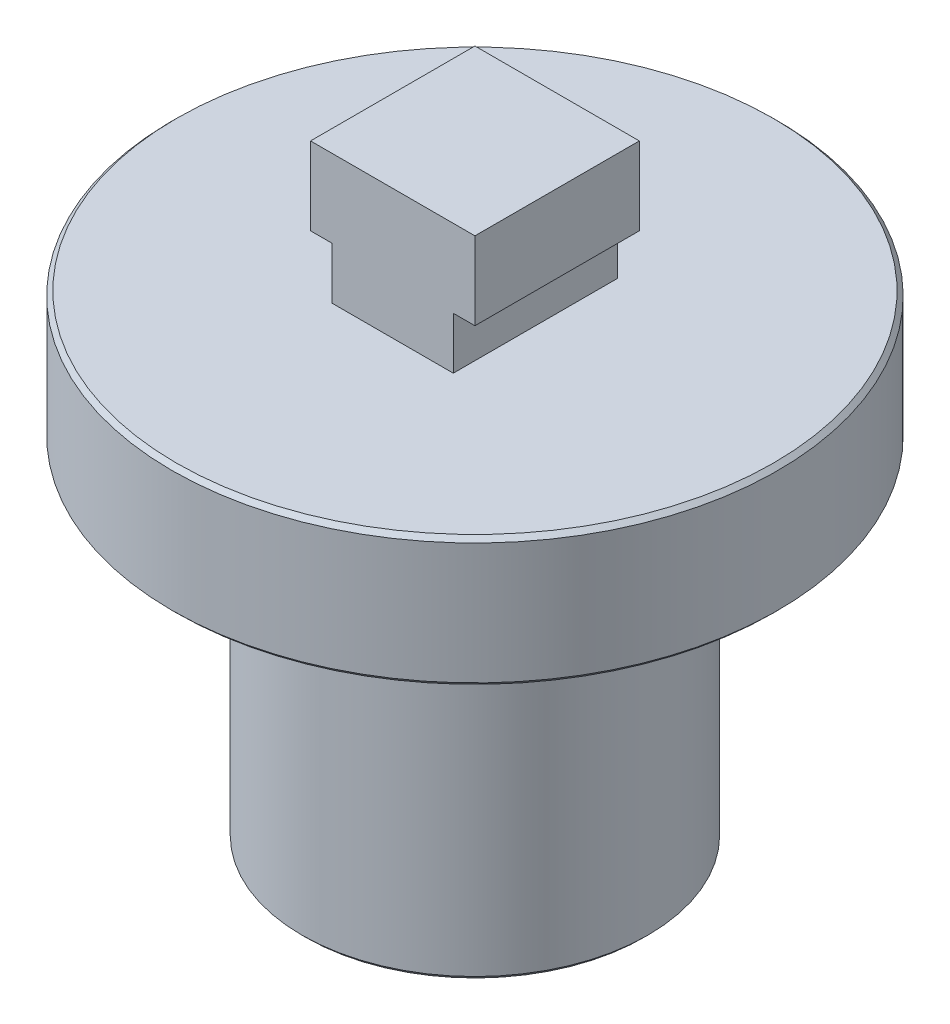
from build123d import *

# Parameters (mm, degrees)
SKETCH1_R           = 4
BOSS_EXTRUDE1_DEPTH = 11
SKETCH2_W           = 3.8
SKETCH2_H           = 3.8
CUT_EXTRUDE1_DEPTH  = 4
SKETCH3_W           = 3.8
SKETCH3_H           = 3.8
BOSS_EXTRUDE2_DEPTH = 3
SKETCH4_W           = 0.5
SKETCH4_H           = 1.2
CUT_EXTRUDE2_DEPTH  = 13
SKETCH5_R           = 7
BOSS_EXTRUDE3_DEPTH = 3
CHAMFER1_SIZE       = 0.1


with BuildPart() as part:
    # Sketch1 → Boss-Extrude1 (new body)
    with BuildSketch(Plane(origin=(0, 0, 0), x_dir=(1, 0, 0), z_dir=(0, 1, 0))):
        Circle(SKETCH1_R)
    extrude(amount=BOSS_EXTRUDE1_DEPTH)

    # Sketch2 → Cut-Extrude1 (cut)
    with BuildSketch(Plane.XZ):
        Rectangle(SKETCH2_W, SKETCH2_H)
    extrude(amount=-CUT_EXTRUDE1_DEPTH, mode=Mode.SUBTRACT)

    # Sketch3 → Boss-Extrude2 (add)
    with BuildSketch(Plane(origin=(0, 11, 0), x_dir=(1, 0, 0), z_dir=(0, 1, 0))):
        Rectangle(SKETCH3_W, SKETCH3_H)
    extrude(amount=BOSS_EXTRUDE2_DEPTH)

    # Sketch4 → Cut-Extrude2 (cut)
    with BuildSketch(Plane.XY.offset(1.9)):
        with Locations((-1.65, 11.6)):
            Rectangle(SKETCH4_W, SKETCH4_H)
        with Locations((1.65, 11.6)):
            Rectangle(SKETCH4_W, SKETCH4_H)
    extrude(amount=-CUT_EXTRUDE2_DEPTH, mode=Mode.SUBTRACT)

    # Sketch5 → Boss-Extrude3 (add)
    with BuildSketch(Plane(origin=(0, 11, 0), x_dir=(1, 0, 0), z_dir=(0, 1, 0))):
        Circle(SKETCH5_R)
    extrude(amount=-BOSS_EXTRUDE3_DEPTH)

    # Chamfer1
    chamfer1_edges = [part.edges().sort_by_distance(p)[0] for p in [
        (-4, 0, 0),
        (-7, 11, 0),
        (-7, 8, 0),
    ]]
    chamfer(chamfer1_edges, length=CHAMFER1_SIZE)


solid = part.part
